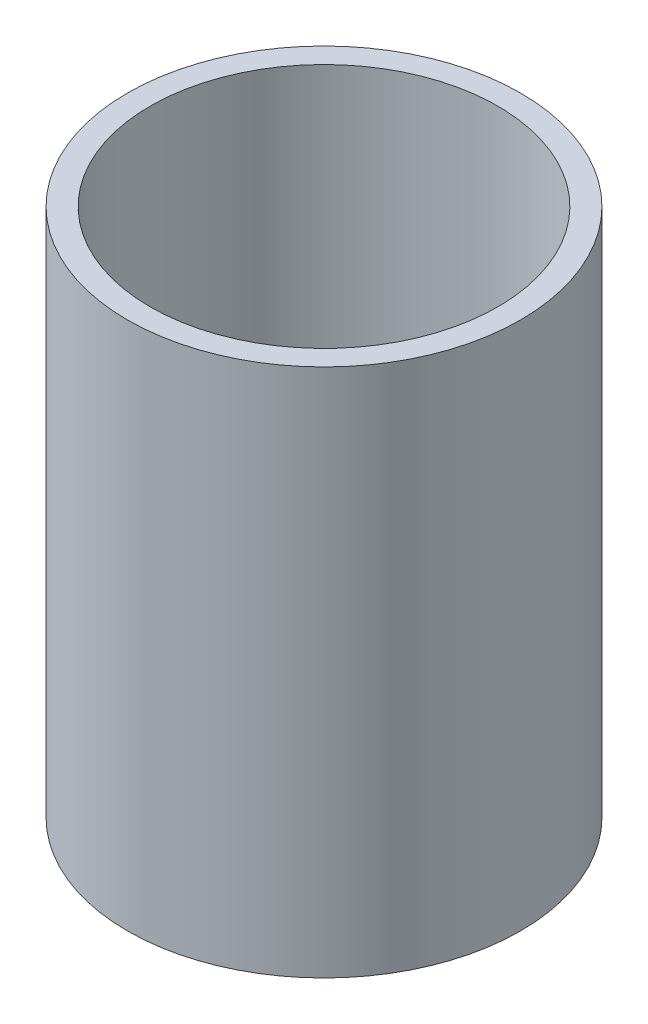
from build123d import *

# Parameters (mm, degrees)
SKETCH1_R           = 26
SKETCH1_R_2         = 23
BOSS_EXTRUDE1_DEPTH = 35


with BuildPart() as part:
    # Sketch1 → Boss-Extrude1 (new body, symmetric)
    with BuildSketch(Plane(origin=(0, 0, 0), x_dir=(1, 0, 0), z_dir=(0, 1, 0))):
        Circle(SKETCH1_R)
        Circle(SKETCH1_R_2, mode=Mode.SUBTRACT)
    extrude(amount=BOSS_EXTRUDE1_DEPTH, both=True)


solid = part.part
